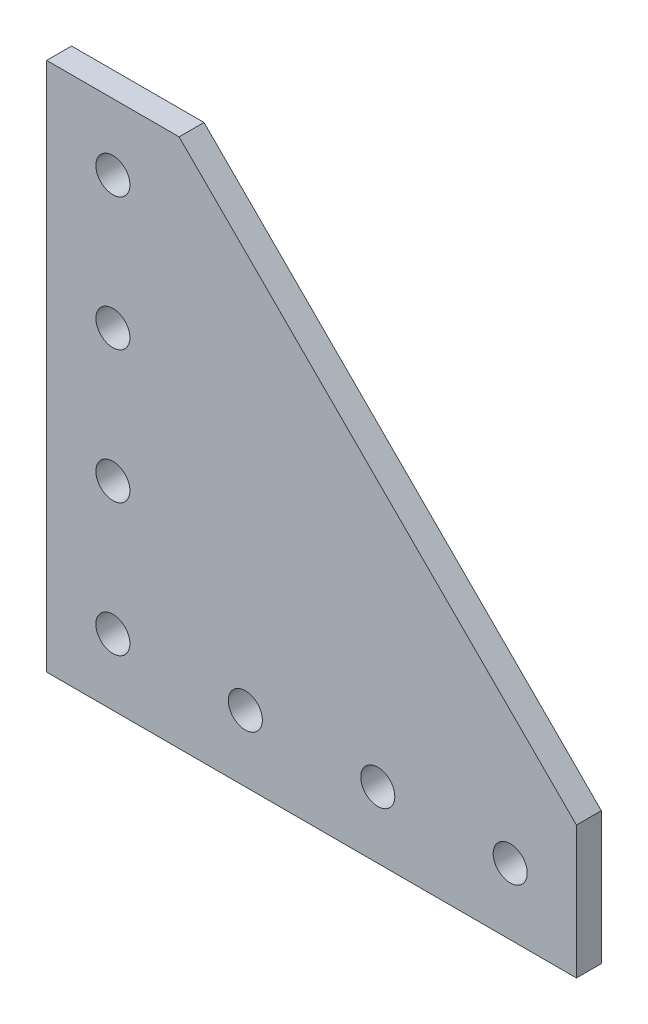
from build123d import *

# Parameters (mm, degrees)
BOSS_EXTRUDE1_DEPTH      = 2.3876
BOSS_EXTRUDE1_DEPTH_BACK = 2.3876
SKETCH4_R                = 3.2639
CUT_EXTRUDE1_DEPTH       = 5.7752


with BuildPart() as part:
    # Sketch3 → Boss-Extrude1 (new body, two sides)
    with BuildSketch(Plane.XY) as boss_extrude1_sk:
        Polygon((50.8, -25.4), (50.8, -50.8), (-50.8, -50.8), (-50.8, 50.8), (-25.4, 50.8), align=None)
    extrude(amount=BOSS_EXTRUDE1_DEPTH)
    extrude(boss_extrude1_sk.sketch, amount=-BOSS_EXTRUDE1_DEPTH_BACK)

    # Sketch4 → Cut-Extrude1 (cut, through all)
    with BuildSketch(Plane.XY.offset(2.3876)):
        with Locations((-38.1, -38.1)):
            Circle(SKETCH4_R)
        with Locations((-12.7, -38.1)):
            Circle(SKETCH4_R)
        with Locations((12.7, -38.1)):
            Circle(SKETCH4_R)
        with Locations((-38.1, -12.7)):
            Circle(SKETCH4_R)
        with Locations((-38.1, 12.7)):
            Circle(SKETCH4_R)
        with Locations((38.1, -38.1)):
            Circle(SKETCH4_R)
        with Locations((-38.1, 38.1)):
            Circle(SKETCH4_R)
    extrude(amount=-CUT_EXTRUDE1_DEPTH, mode=Mode.SUBTRACT)


solid = part.part
